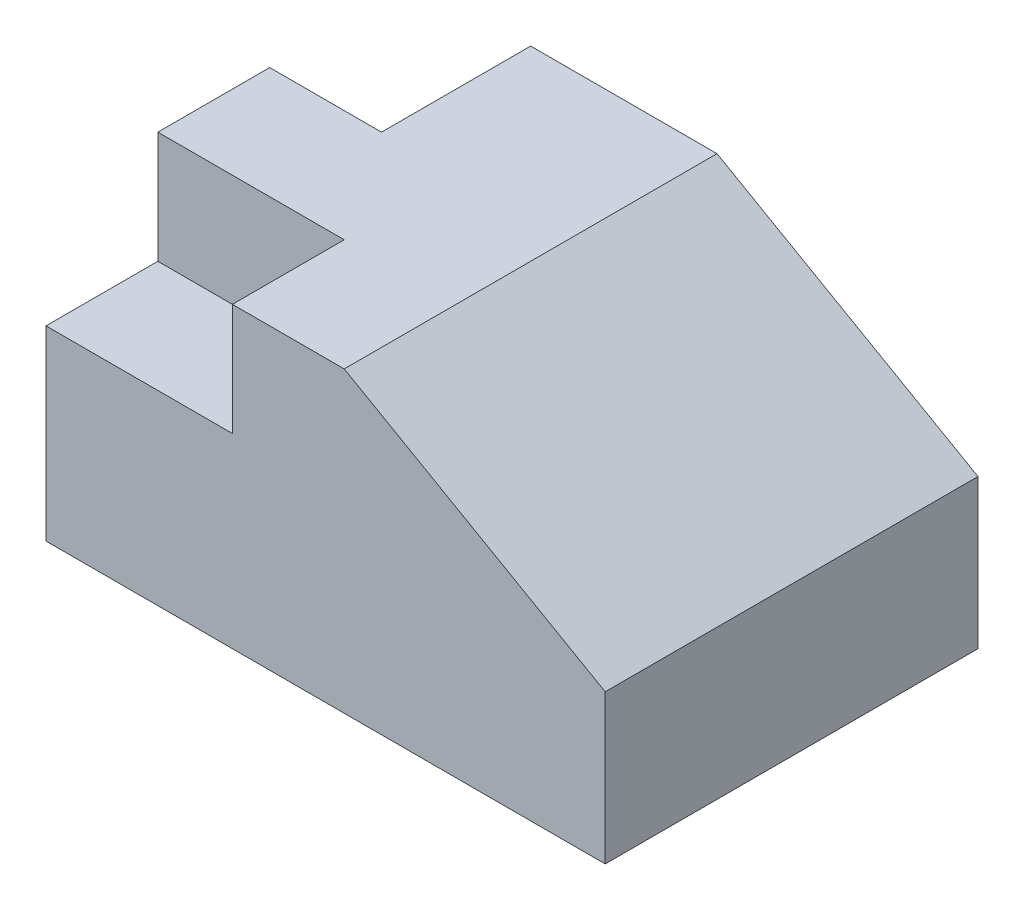
from build123d import *

# Parameters (mm, degrees)
SKETCH1_W           = 150
SKETCH1_H           = 100
BOSS_EXTRUDE1_DEPTH = 80
CUT_EXTRUDE1_DEPTH  = 101
SKETCH3_W           = 50
SKETCH3_H           = 30
SKETCH3_W_2         = 30
SKETCH3_H_2         = 40
CUT_EXTRUDE2_DEPTH  = 30


with BuildPart() as part:
    # Sketch1 → Boss-Extrude1 (new body)
    with BuildSketch(Plane(origin=(0, 0, 0), x_dir=(1, 0, 0), z_dir=(0, 1, 0))):
        Rectangle(SKETCH1_W, SKETCH1_H)
    extrude(amount=BOSS_EXTRUDE1_DEPTH)

    # Sketch2 → Cut-Extrude1 (cut, through all)
    with BuildSketch(Plane.XY.offset(50)):
        Polygon((75, 80), (5, 80), (75, 40), align=None)
    extrude(amount=-CUT_EXTRUDE1_DEPTH, mode=Mode.SUBTRACT)

    # Sketch3 → Cut-Extrude2 (cut)
    with BuildSketch(Plane(origin=(0, 80, 0), x_dir=(1, 0, 0), z_dir=(0, 1, 0))):
        with Locations((-50, -35)):
            Rectangle(SKETCH3_W, SKETCH3_H)
        with Locations((-60, 30)):
            Rectangle(SKETCH3_W_2, SKETCH3_H_2)
    extrude(amount=-CUT_EXTRUDE2_DEPTH, mode=Mode.SUBTRACT)


solid = part.part
